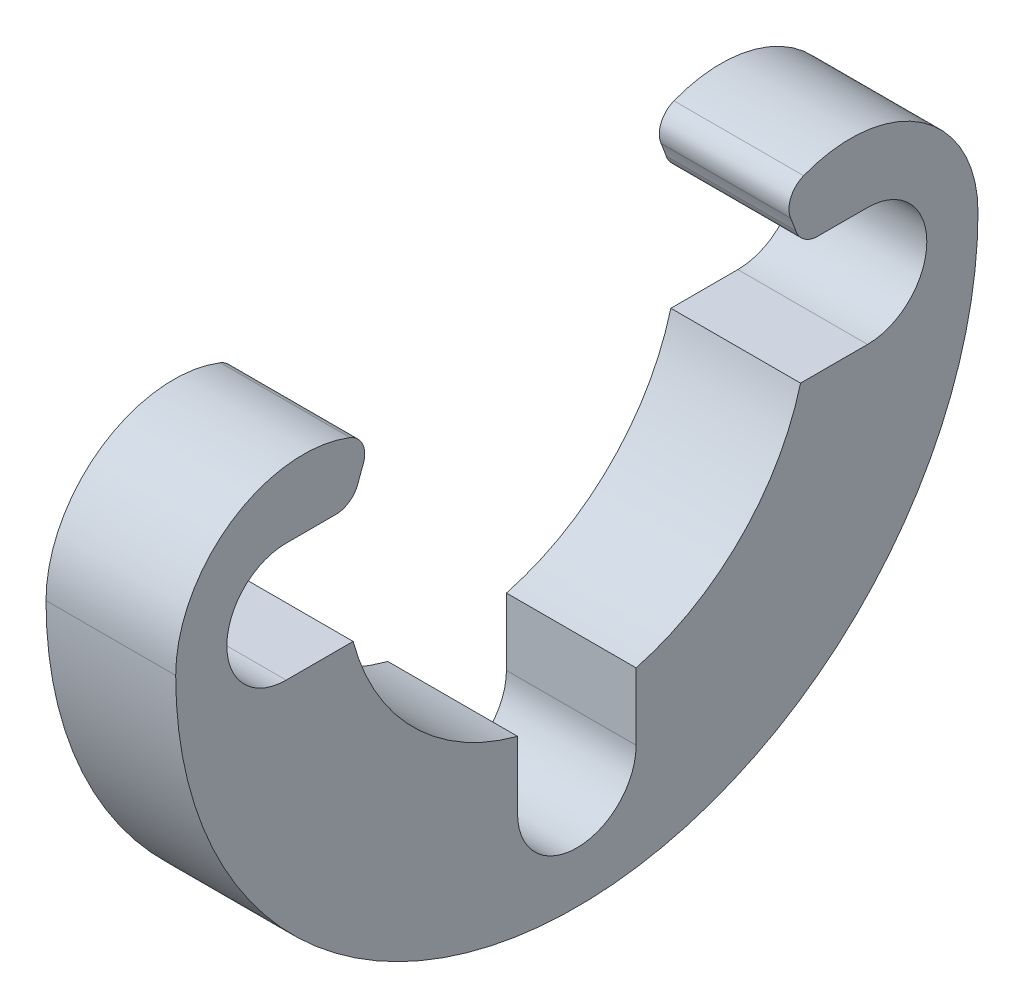
from build123d import *

# Parameters (mm, degrees)
SKETCH2_R          = 1.6256
CUT_EXTRUDE1_DEPTH = 3.556
CIRPATTERN1_COUNT  = 4
CUT_EXTRUDE2_DEPTH = 3.556
SKETCH4_R          = 4.99999
CUT_EXTRUDE3_DEPTH = 10
CUT_EXTRUDE4_DEPTH = 3.556
SKETCH6_R          = 5.08
CUT_EXTRUDE5_DEPTH = 1.5824
CUT_EXTRUDE6_DEPTH = 4.556
FILLET1_R          = 0.635


with BuildPart() as part:
    # Sketch1 → Revolve1 (revolve)
    with BuildSketch(Plane.XY):
        Polygon((-15.1384, 4.99999), (-5.1384, 4.99999), (-5.1384, 11), (-1.5824, 11), (-1.5824, 5.08), (0, 5.08), (0, 4), (-15.1384, 4), align=None)
    revolve(axis=Axis((0, 0, 0), (-1, 0, 0)))

    # Sketch2 → Cut-Extrude1 (cut)
    with BuildSketch(Plane(origin=(-1.5824, 0, 0), x_dir=(0, 0, -1), z_dir=(1, 0, 0))):
        with Locations((0, 7.97105)):
            Circle(SKETCH2_R)
    cut_extrude1 = extrude(amount=-CUT_EXTRUDE1_DEPTH, mode=Mode.SUBTRACT)

    # CirPattern1: Cut-Extrude1 ×4 about axis
    cirpattern1_axis = Axis((0, 0, 0), (1, 0, 0))
    for i in range(1, CIRPATTERN1_COUNT):
        add(cut_extrude1.rotate(cirpattern1_axis, i * 360 / CIRPATTERN1_COUNT), mode=Mode.SUBTRACT)

    # Sketch3 → Cut-Extrude2 (cut)
    with BuildSketch(Plane(origin=(-1.5824, 0, 0), x_dir=(0, 0, -1), z_dir=(1, 0, 0))):
        with BuildLine():
            Line((-4.215969639, 10.16), (4.215969639, 10.16))
            ThreePointArc((4.215969639, 10.16), (0, 11), (-4.215969639, 10.16))
        make_face()
    extrude(amount=-CUT_EXTRUDE2_DEPTH, mode=Mode.SUBTRACT)

    # Sketch4 → Cut-Extrude3 (cut)
    with BuildSketch(Plane.ZY.offset(15.1384)):
        Circle(SKETCH4_R)
    extrude(amount=-CUT_EXTRUDE3_DEPTH, mode=Mode.SUBTRACT)

    # Sketch5 → Cut-Extrude4 (cut)
    with BuildSketch(Plane.ZY.offset(5.1384)):
        with BuildLine():
            ThreePointArc((-4, 0), (-7.5, 3.5), (-11, 0))
            ThreePointArc((-11, 0), (0, 11), (11, 0))
            ThreePointArc((11, 0), (7.5, 3.5), (4, 0))
            ThreePointArc((4, 0), (0, 4), (-4, 0))
        make_face()
    extrude(amount=-CUT_EXTRUDE4_DEPTH, mode=Mode.SUBTRACT)

    # Sketch6 → Cut-Extrude5 (cut)
    with BuildSketch(Plane(origin=(0, 0, 0), x_dir=(0, 0, -1), z_dir=(1, 0, 0))):
        Circle(SKETCH6_R)
    extrude(amount=-CUT_EXTRUDE5_DEPTH, mode=Mode.SUBTRACT)

    # Sketch7 → Cut-Extrude6 (cut, through all)
    with BuildSketch(Plane.ZY.offset(5.1384)):
        with BuildLine():
            Line((-7.97105, 1.6256), (-6.133690597, 1.6256))
            ThreePointArc((-6.133690597, 1.6256), (0, 6.34545), (6.133690597, 1.6256))
            Line((6.133690597, 1.6256), (7.97105, 1.6256))
            ThreePointArc((7.97105, 1.6256), (6.34545, 0), (7.97105, -1.6256))
            Line((7.97105, -1.6256), (6.133690597, -1.6256))
            ThreePointArc((6.133690597, -1.6256), (4.486910725, -4.486910725), (1.6256, -6.133690597))
            Line((1.6256, -6.133690597), (1.6256, -7.97105))
            ThreePointArc((1.6256, -7.97105), (0, -6.34545), (-1.6256, -7.97105))
            Line((-1.6256, -7.97105), (-1.6256, -6.133690597))
            ThreePointArc((-1.6256, -6.133690597), (-4.486910725, -4.486910725), (-6.133690597, -1.6256))
            Line((-6.133690597, -1.6256), (-7.97105, -1.6256))
            ThreePointArc((-7.97105, -1.6256), (-6.34545, 0), (-7.97105, 1.6256))
        make_face()
    extrude(amount=-CUT_EXTRUDE6_DEPTH, mode=Mode.SUBTRACT)

    # Fillet1
    fillet1_edges = [part.edges().sort_by_distance(p)[0] for p in [
        (-3.3604, 2.95072108, 5.617649047),
        (-3.3604, 1.6256, -6.133690597),
        (-3.3604, 1.6256, 6.133690597),
        (-3.3604, 2.95072108, -5.617649047),
    ]]
    fillet(fillet1_edges, radius=FILLET1_R)


solid = part.part
